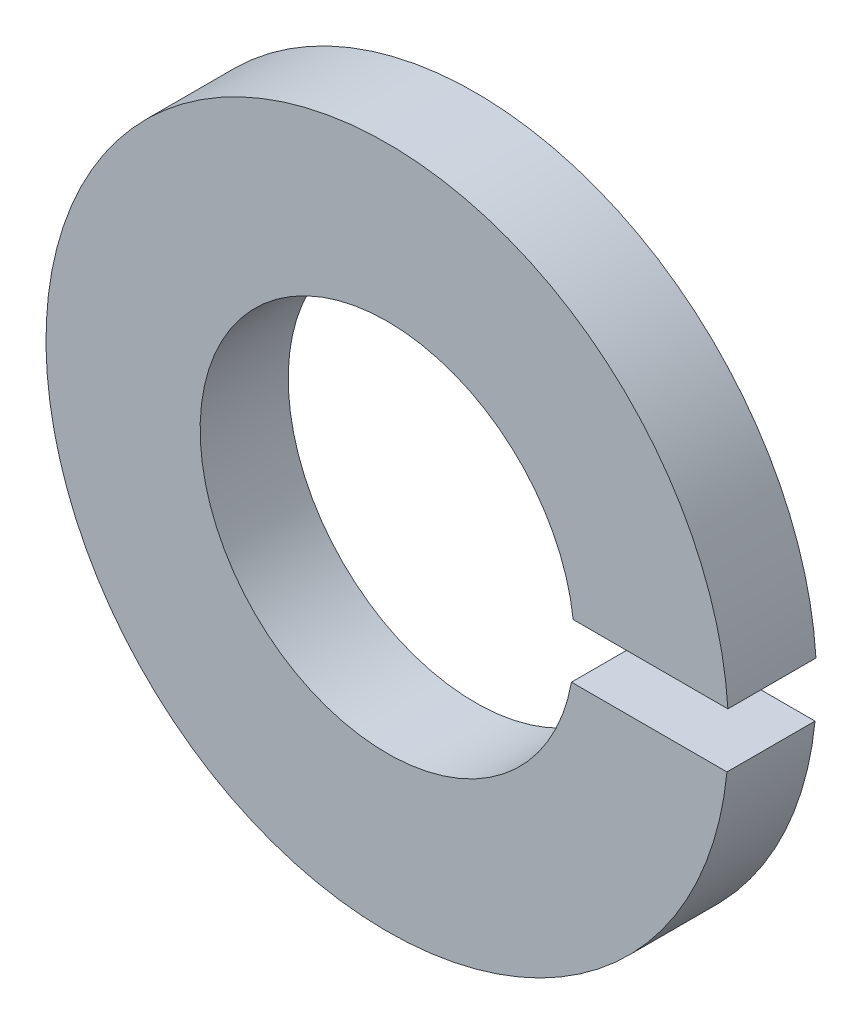
from build123d import *

# Parameters (mm, degrees)
BOSS_EXTRUDE1_DEPTH = 0.8


with BuildPart() as part:
    # Sketch1 → Boss-Extrude1 (new body)
    with BuildSketch(Plane.XY):
        with BuildLine():
            ThreePointArc((3.093684426, 0.197779353), (-3.09955725, 0.052391341), (3.085233003, -0.302220647))
            Line((3.085233003, -0.302220647), (1.672920405, -0.302220647))
            ThreePointArc((1.672920405, -0.302220647), (-1.699179998, 0.052795207), (1.6884559, 0.197779353))
            Line((1.6884559, 0.197779353), (3.093684426, 0.197779353))
        make_face()
    extrude(amount=BOSS_EXTRUDE1_DEPTH)


solid = part.part
